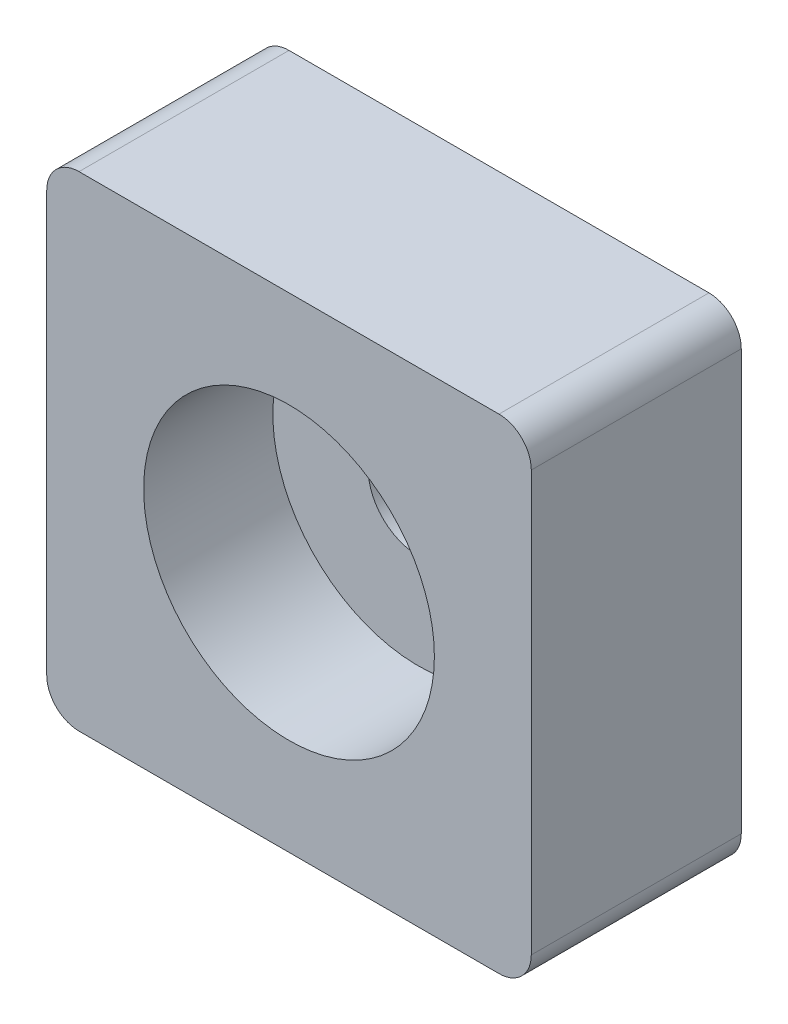
from build123d import *

# Parameters (mm, degrees)
SKETCH1_W           = 30
SKETCH1_H           = 30
SKETCH1_R           = 3.1
BOSS_EXTRUDE1_DEPTH = 13
SKETCH2_R           = 9
CUT_EXTRUDE1_DEPTH  = 8
FILLET1_R           = 2


with BuildPart() as part:
    # Sketch1 → Boss-Extrude1 (new body)
    with BuildSketch(Plane.XY):
        Rectangle(SKETCH1_W, SKETCH1_H)
        Circle(SKETCH1_R, mode=Mode.SUBTRACT)
    extrude(amount=BOSS_EXTRUDE1_DEPTH)

    # Sketch2 → Cut-Extrude1 (cut)
    with BuildSketch(Plane.XY.offset(13)):
        Circle(SKETCH2_R)
    extrude(amount=-CUT_EXTRUDE1_DEPTH, mode=Mode.SUBTRACT)

    # Fillet1
    fillet1_edges = [part.edges().sort_by_distance(p)[0] for p in [
        (15, -15, 6.5),
        (-15, -15, 6.5),
        (-15, 15, 6.5),
        (15, 15, 6.5),
    ]]
    fillet(fillet1_edges, radius=FILLET1_R)


solid = part.part
